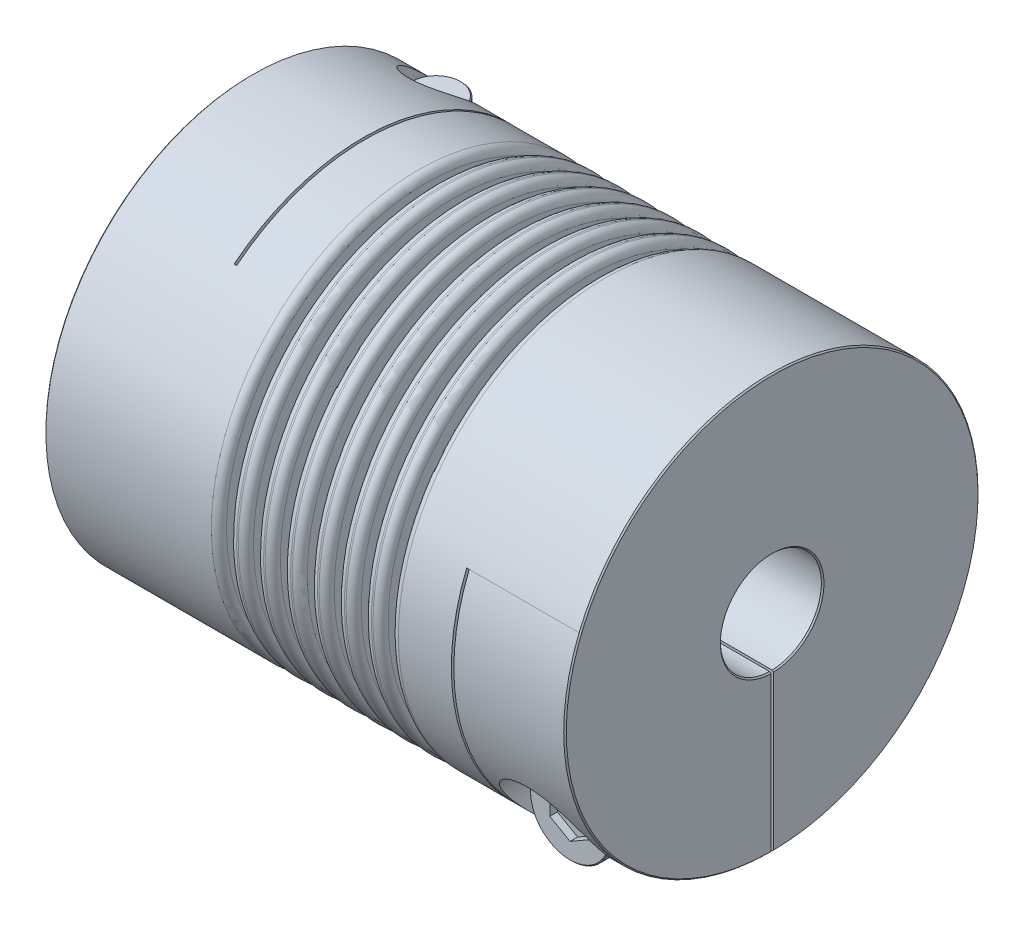
from build123d import *

# Parameters (mm, degrees)
SKETCH1_R                       = 41
BOSS_EXTRUDE1_DEPTH             = 51.5
SKETCH2_R                       = 10
CUT_EXTRUDE1_DEPTH              = 119.198984767
CHAMFER1_SIZE                   = 0.254
SKETCH4_W                       = 0.5
SKETCH4_H                       = 66.5
CUT_EXTRUDE2_DEPTH              = 106.153459287
SKETCH7_W                       = 0.5
SKETCH7_H                       = 56.5
CUT_EXTRUDE3_DEPTH              = 106.153459287
SKETCH8_W                       = 22
SKETCH8_H                       = 41
CUT_EXTRUDE5_DEPTH              = 0.25
SKETCH13_W                      = 22
SKETCH13_H                      = 41
CUT_EXTRUDE6_DEPTH              = 0.25
CBORE_FOR_M10_SHCS2_D           = 11
CBORE_FOR_M10_SHCS2_CBORE_D     = 18
CBORE_FOR_M10_SHCS2_CBORE_DEPTH = 20
CBORE_FOR_M10_SHCS1_D           = 11
CBORE_FOR_M10_SHCS1_CBORE_D     = 18
CBORE_FOR_M10_SHCS1_CBORE_DEPTH = 22
SKETCH16_R                      = 8
BOSS_EXTRUDE2_DEPTH             = 10
SKETCH17_R                      = 5
BOSS_EXTRUDE3_DEPTH             = 49
CHAMFER2_SIZE                   = 0.2
CUT_EXTRUDE7_DEPTH              = 1.5
CIRPATTERN1_COUNT               = 2
CIRPATTERN1_ANGLE               = 90
SKETCH19_W                      = 2
SKETCH19_H                      = 13
FILLET1_R                       = 1.5
FILLET2_R                       = 0.1


with BuildPart() as part:
    # Sketch1 → Boss-Extrude1 (new, symmetric)
    with BuildSketch(Plane(origin=(0, 0, 0), x_dir=(0, 0, -1), z_dir=(1, 0, 0))):
        Circle(SKETCH1_R)
    extrude(amount=BOSS_EXTRUDE1_DEPTH, both=True)

    # Sketch2 → Cut-Extrude1 (cut, through all)
    with BuildSketch(Plane(origin=(51.5, 0, 0), x_dir=(0, 0, -1), z_dir=(1, 0, 0))):
        Circle(SKETCH2_R)
    extrude(amount=-CUT_EXTRUDE1_DEPTH, mode=Mode.SUBTRACT)

    # Chamfer1
    chamfer1_edges = [part.edges().sort_by_distance(p)[0] for p in [
        (-51.5, 0, 41),
        (51.5, 0, 41),
        (-51.5, 0, 10),
        (51.5, 0, 10),
    ]]
    chamfer(chamfer1_edges, length=CHAMFER1_SIZE)

    # Sketch4 → Cut-Extrude2 (cut, through all)
    with BuildSketch(Plane.XZ.offset(41)):
        with Locations((-29.25, -7.75)):
            Rectangle(SKETCH4_W, SKETCH4_H)
    extrude(amount=-CUT_EXTRUDE2_DEPTH, mode=Mode.SUBTRACT)

    # Sketch7 → Cut-Extrude3 (cut, through all)
    with BuildSketch(Plane(origin=(0, 0, -41), x_dir=(-1, 0, 0), z_dir=(0, 0, -1))):
        with Locations((-29.25, -12.75)):
            Rectangle(SKETCH7_W, SKETCH7_H)
    extrude(amount=-CUT_EXTRUDE3_DEPTH, mode=Mode.SUBTRACT)

    # Sketch8 → Cut-Extrude5 (cut, symmetric)
    with BuildSketch(Plane(origin=(0, 0, 0), x_dir=(1, 0, 0), z_dir=(0, 1, 0))):
        with Locations((-40.5, 20.5)):
            Rectangle(SKETCH8_W, SKETCH8_H)
    extrude(amount=CUT_EXTRUDE5_DEPTH, both=True, mode=Mode.SUBTRACT)

    # Sketch13 → Cut-Extrude6 (cut, symmetric)
    with BuildSketch(Plane.XY):
        with Locations((40.5, -20.5)):
            Rectangle(SKETCH13_W, SKETCH13_H)
    extrude(amount=CUT_EXTRUDE6_DEPTH, both=True, mode=Mode.SUBTRACT)

    # CBORE for M10 SHCS2 (through all)
    with Locations(Plane.XZ.offset(41)):
        with Locations((-40.5, -25.498056155)):
            CounterBoreHole(CBORE_FOR_M10_SHCS2_D / 2, CBORE_FOR_M10_SHCS2_CBORE_D / 2, CBORE_FOR_M10_SHCS2_CBORE_DEPTH)

    # CBORE for M10 SHCS1 (through all)
    with Locations(Plane.XY.offset(41)):
        with Locations((40.5, -25.498056155)):
            CounterBoreHole(CBORE_FOR_M10_SHCS1_D / 2, CBORE_FOR_M10_SHCS1_CBORE_D / 2, CBORE_FOR_M10_SHCS1_CBORE_DEPTH)

    # Sketch19 → Cut-Revolve1 (revolve, cut)
    with BuildSketch(Plane.XY):
        with Locations((0, 34.5)):
            Rectangle(SKETCH19_W, SKETCH19_H)
        with Locations((5.333333333, 34.5)):
            Rectangle(SKETCH19_W, SKETCH19_H)
        with Locations((10.666666667, 34.5)):
            Rectangle(SKETCH19_W, SKETCH19_H)
        with Locations((16, 34.5)):
            Rectangle(SKETCH19_W, SKETCH19_H)
        with Locations((-16, 34.5)):
            Rectangle(SKETCH19_W, SKETCH19_H)
        with Locations((-10.666666667, 34.5)):
            Rectangle(SKETCH19_W, SKETCH19_H)
        with Locations((-5.333333333, 34.5)):
            Rectangle(SKETCH19_W, SKETCH19_H)
    revolve(axis=Axis((0, 0, 0), (-1, 0, 0)), mode=Mode.SUBTRACT)

    # Fillet1
    fillet1_edges = [part.edges().sort_by_distance(p)[0] for p in [
        (1, 0, 41),
        (-1, 0, 41),
        (-17, 0, 41),
        (-15, 0, 41),
        (6.333333333, 0, 41),
        (4.333333333, 0, 41),
        (11.666666667, 0, 41),
        (9.666666667, 0, 41),
        (17, 0, 41),
        (15, 0, 41),
        (-11.666666667, 0, 41),
        (-9.666666667, 0, 41),
        (-6.333333333, 0, 41),
        (-4.333333333, 0, 41),
    ]]
    fillet(fillet1_edges, radius=FILLET1_R)

    # Fillet2
    fillet2_edges = [part.edges().sort_by_distance(p)[0] for p in [
        (-1, -28, 0),
        (1, -28, 0),
        (-17, -28, 0),
        (-15, -28, 0),
        (4.333333333, -28, 0),
        (6.333333333, -28, 0),
        (9.666666667, -28, 0),
        (11.666666667, -28, 0),
        (15, -28, 0),
        (17, -28, 0),
        (-11.666666667, -28, 0),
        (-9.666666667, -28, 0),
        (-6.333333333, -28, 0),
        (-4.333333333, -28, 0),
    ]]
    fillet(fillet2_edges, radius=FILLET2_R)


with BuildPart() as body_2:
    # Sketch16 → Boss-Extrude2 (new body)
    with BuildSketch(Plane.XY.offset(19)):
        with Locations((40.5, -25.498056155)):
            Circle(SKETCH16_R)
    extrude(amount=BOSS_EXTRUDE2_DEPTH)

    # Sketch17 → Boss-Extrude3 (add)
    with BuildSketch(Plane(origin=(0, 0, 19), x_dir=(-1, 0, 0), z_dir=(0, 0, -1))):
        with Locations(Location((-40.5, -25.498056155, 0), (0, 0, 180))):
            Circle(SKETCH17_R)
    extrude(amount=BOSS_EXTRUDE3_DEPTH)

    # Chamfer2
    chamfer2_edges = [body_2.edges().sort_by_distance(p)[0] for p in [
        (32.5, -25.498056155, 19),
        (32.5, -25.498056155, 29),
        (35.5, -25.498056155, -30),
    ]]
    chamfer(chamfer2_edges, length=CHAMFER2_SIZE)

    # Sketch18 → Cut-Extrude7 (cut)
    with BuildSketch(Plane.XY.offset(29)):
        Polygon((40.5, -30.116858308), (44.5, -27.807457231), (44.5, -23.188655078), (40.5, -20.879254001), (36.5, -23.188655078), (36.5, -27.807457231), align=None)
    extrude(amount=-CUT_EXTRUDE7_DEPTH, mode=Mode.SUBTRACT)


with BuildPart() as body_3:
    # Mirror1: mirrored copy
    add(body_2.part.mirror(Plane(origin=(0, 0, 0), x_dir=(0, 0, 1), z_dir=(1, 0, 0))))


with BuildPart() as cirpattern1_1:
    # CirPattern1: pattern copy
    add(body_3.part.rotate(Axis((0, 0, 0), (1, 0, 0)), 1 * CIRPATTERN1_ANGLE / (CIRPATTERN1_COUNT - 1)))


solid = Compound([part.part, body_2.part, cirpattern1_1.part])
